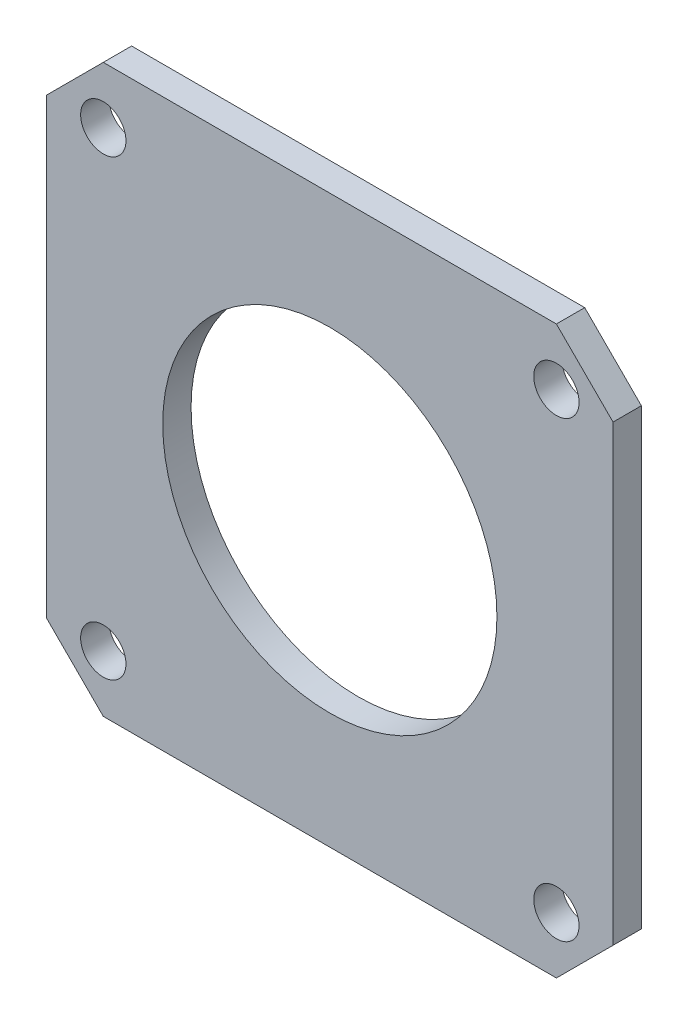
from build123d import *

# Parameters (mm, degrees)
SKETCH2_R           = 29.5
SKETCH2_R_2         = 4
BOSS_EXTRUDE2_DEPTH = 5


with BuildPart() as part:
    # Sketch2 → Boss-Extrude2 (new body)
    with BuildSketch(Plane.XY):
        Polygon((-40, 50), (-50, 40), (-50, -40), (-40, -50), (40, -50), (50, -40), (50, 40), (40, 50), align=None)
        Circle(SKETCH2_R, mode=Mode.SUBTRACT)
        with Locations((-40, 40)):
            Circle(SKETCH2_R_2, mode=Mode.SUBTRACT)
        with Locations((40, 40)):
            Circle(SKETCH2_R_2, mode=Mode.SUBTRACT)
        with Locations((40, -40)):
            Circle(SKETCH2_R_2, mode=Mode.SUBTRACT)
        with Locations((-40, -40)):
            Circle(SKETCH2_R_2, mode=Mode.SUBTRACT)
    extrude(amount=BOSS_EXTRUDE2_DEPTH)


solid = part.part
